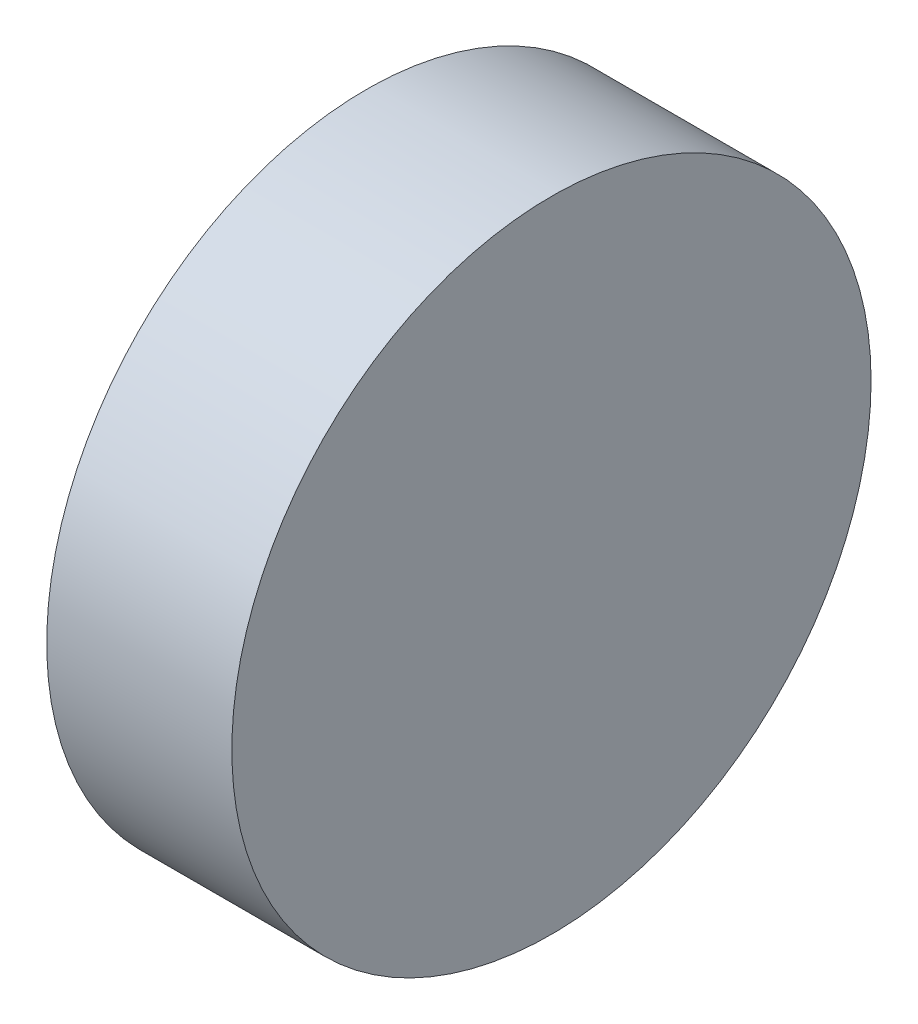
from build123d import *

# Parameters (mm, degrees)
CROQUIS2_W = 35.320702992
CROQUIS2_H = 60.992050732
VACIADO1_T = -0.5


with BuildPart() as part:
    # Croquis2 → Revolución1 (revolve)
    with BuildSketch(Plane.XY):
        with Locations((17.660351496, 30.496025366)):
            Rectangle(CROQUIS2_W, CROQUIS2_H)
    revolve(axis=Axis((35.320702992, 0, 0), (-1, 0, 0)))

    # Vaciado1
    vaciado1_openings = [part.faces().sort_by_distance(p)[0] for p in [
        (0, 0, -60.992050732),
    ]]
    offset(amount=VACIADO1_T, openings=vaciado1_openings, kind=Kind.INTERSECTION)


solid = part.part
